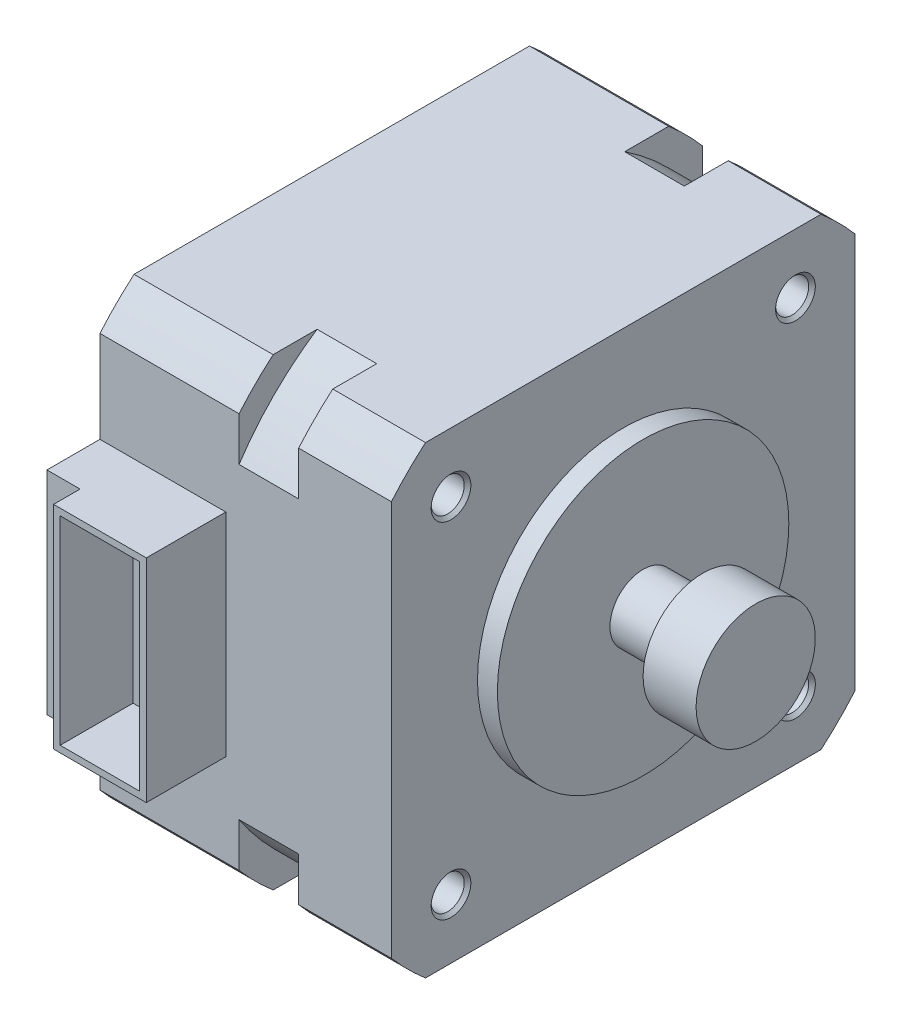
from build123d import *

# Parameters (mm, degrees)
BOSS_EXTRUDE1_DEPTH       = 10.5
BOSS_EXTRUDE2_DEPTH       = 4.5
BOSS_EXTRUDE3_DEPTH       = 7
SKETCH4_W                 = 9.5
SKETCH4_H                 = 16
BOSS_EXTRUDE4_DEPTH       = 6
SKETCH5_W                 = 2.5
SKETCH5_H                 = 2
CUT_EXTRUDE1_DEPTH        = 26.5
SKETCH6_W                 = 6
SKETCH6_H                 = 15
CUT_EXTRUDE2_DEPTH        = 5.5
F_2_CLEARANCE_HOLE1_D     = 2.5
F_2_CLEARANCE_HOLE1_DEPTH = 22
CHAMFER1_SIZE             = 0.25


with BuildPart() as part:
    # Sketch1 → Boss-Extrude1 (new body)
    with BuildSketch(Plane(origin=(0, 0, 0), x_dir=(0, -1, 0), z_dir=(-1, 0, 0))):
        with BuildLine():
            Line((14.924811557, 17.5), (-14.924811557, 17.5))
            ThreePointArc((-14.924811557, 17.5), (-16.263455967, 16.263455967), (-17.5, 14.924811557))
            Line((-17.5, 14.924811557), (-17.5, -14.924811557))
            ThreePointArc((-17.5, -14.924811557), (-16.263455967, -16.263455967), (-14.924811557, -17.5))
            Line((-14.924811557, -17.5), (14.924811557, -17.5))
            ThreePointArc((14.924811557, -17.5), (16.263455967, -16.263455967), (17.5, -14.924811557))
            Line((17.5, -14.924811557), (17.5, 14.924811557))
            ThreePointArc((17.5, 14.924811557), (16.263455967, 16.263455967), (14.924811557, 17.5))
        make_face()
    extrude(amount=-BOSS_EXTRUDE1_DEPTH)

    # Sketch2 → Boss-Extrude2 (add)
    with BuildSketch(Plane(origin=(10.5, 0, 0), x_dir=(0, 0, -1), z_dir=(1, 0, 0))):
        with BuildLine():
            Line((-17.5, -11.608186766), (-17.5, 11.608186766))
            ThreePointArc((-17.5, 11.608186766), (-14.849242405, 14.849242405), (-11.608186766, 17.5))
            Line((-11.608186766, 17.5), (11.608186766, 17.5))
            ThreePointArc((11.608186766, 17.5), (14.849242405, 14.849242405), (17.5, 11.608186766))
            Line((17.5, 11.608186766), (17.5, -11.608186766))
            ThreePointArc((17.5, -11.608186766), (14.849242405, -14.849242405), (11.608186766, -17.5))
            Line((11.608186766, -17.5), (-11.608186766, -17.5))
            ThreePointArc((-11.608186766, -17.5), (-14.849242405, -14.849242405), (-17.5, -11.608186766))
        make_face()
    extrude(amount=BOSS_EXTRUDE2_DEPTH)

    # Sketch3 → Boss-Extrude3 (add)
    with BuildSketch(Plane(origin=(15, 0, 0), x_dir=(0, 0, -1), z_dir=(1, 0, 0))):
        with BuildLine():
            Line((17.5, 14.924811557), (17.5, -14.924811557))
            ThreePointArc((17.5, -14.924811557), (16.263455967, -16.263455967), (14.924811557, -17.5))
            Line((14.924811557, -17.5), (-14.924811557, -17.5))
            ThreePointArc((-14.924811557, -17.5), (-16.263455967, -16.263455967), (-17.5, -14.924811557))
            Line((-17.5, -14.924811557), (-17.5, 14.924811557))
            ThreePointArc((-17.5, 14.924811557), (-16.263455967, 16.263455967), (-14.924811557, 17.5))
            Line((-14.924811557, 17.5), (14.924811557, 17.5))
            ThreePointArc((14.924811557, 17.5), (16.263455967, 16.263455967), (17.5, 14.924811557))
        make_face()
    extrude(amount=BOSS_EXTRUDE3_DEPTH)

    # Sketch4 → Boss-Extrude4 (add)
    with BuildSketch(Plane.XY.offset(17.5)):
        with Locations((4.75, 0)):
            Rectangle(SKETCH4_W, SKETCH4_H)
    extrude(amount=BOSS_EXTRUDE4_DEPTH)

    # Sketch5 → Cut-Extrude1 (cut, through all)
    with BuildSketch(Plane.XZ.offset(8)):
        with Locations((1.25, 22.5)):
            Rectangle(SKETCH5_W, SKETCH5_H)
    extrude(amount=-CUT_EXTRUDE1_DEPTH, mode=Mode.SUBTRACT)

    # Sketch6 → Cut-Extrude2 (cut)
    with BuildSketch(Plane.XY.offset(23.5)):
        with Locations((6, 0)):
            Rectangle(SKETCH6_W, SKETCH6_H)
    extrude(amount=-CUT_EXTRUDE2_DEPTH, mode=Mode.SUBTRACT)

    # Sketch7 → Revolve1 (revolve)
    with BuildSketch(Plane(origin=(0, 0, 0), x_dir=(-1, 0, 0), z_dir=(0, 0, -1))):
        Polygon((-32, 4.5), (-32, 0), (-22, 0), (-22, 11), (-23.5, 11), (-23.5, 2.5), (-28, 2.5), (-28, 4.5), align=None)
    revolve(axis=Axis((32, 0, 0), (-1, 0, 0)))

    # #2 Clearance Hole1
    with Locations(Plane(origin=(22, 0, 0), x_dir=(0, 0, -1), z_dir=(1, 0, 0))):
        with Locations((-13, 13), (13, 13), (13, -13), (-13, -13)):
            Hole(F_2_CLEARANCE_HOLE1_D / 2, depth=F_2_CLEARANCE_HOLE1_DEPTH)

    # Chamfer1
    chamfer1_edges = [part.edges().sort_by_distance(p)[0] for p in [
        (22, -13, 11.75),
        (0, -13, 11.75),
        (22, -13, -14.25),
        (0, -13, -14.25),
        (22, 13, -14.25),
        (0, 13, -14.25),
        (22, 13, 11.75),
        (0, 13, 11.75),
    ]]
    chamfer(chamfer1_edges, length=CHAMFER1_SIZE)


solid = part.part
